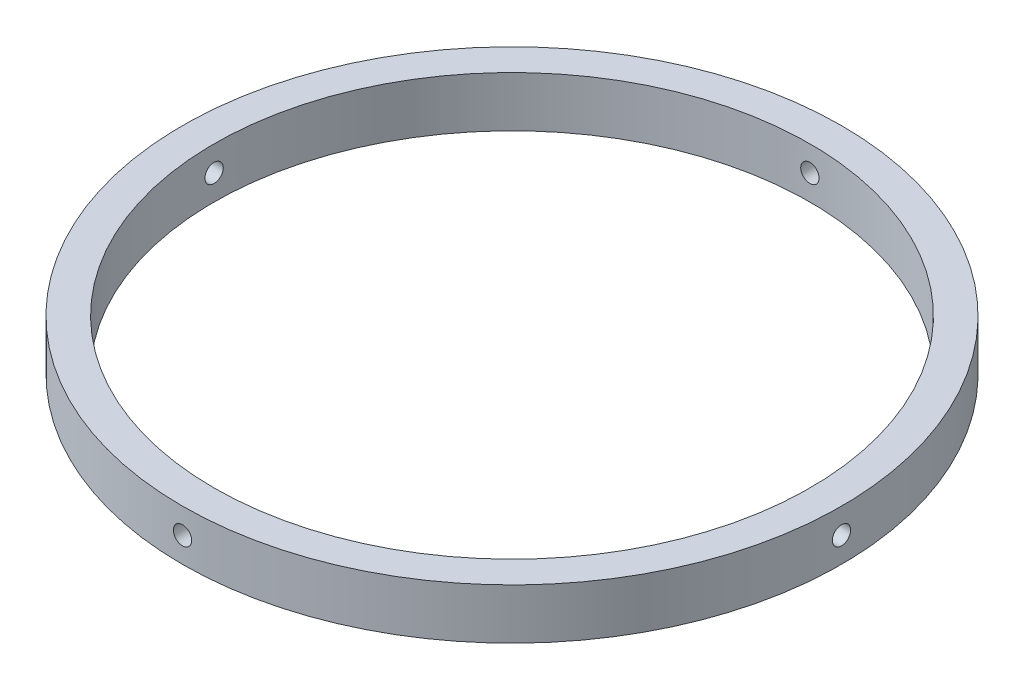
from build123d import *

# Parameters (mm, degrees)
SKETCH1_R               = 52.25
SKETCH1_R_2             = 47.25
BOSS_EXTRUDE1_DEPTH     = 8
SKETCH2_R               = 1.45
CUT_EXTRUDE1_DEPTH      = 53.25
CUT_EXTRUDE1_DEPTH_BACK = 53.25
SKETCH3_R               = 1.45
CUT_EXTRUDE2_DEPTH      = 53.2500001
CUT_EXTRUDE2_DEPTH_BACK = 53.2500001


with BuildPart() as part:
    # Sketch1 → Boss-Extrude1 (new body)
    with BuildSketch(Plane(origin=(0, 0, 0), x_dir=(1, 0, 0), z_dir=(0, 1, 0))):
        Circle(SKETCH1_R)
        Circle(SKETCH1_R_2, mode=Mode.SUBTRACT)
    extrude(amount=BOSS_EXTRUDE1_DEPTH)

    # Sketch2 → Cut-Extrude1 (cut, two sides)
    with BuildSketch(Plane.XY) as cut_extrude1_sk:
        with Locations((0, 4)):
            Circle(SKETCH2_R)
    extrude(amount=CUT_EXTRUDE1_DEPTH, mode=Mode.SUBTRACT)
    extrude(cut_extrude1_sk.sketch, amount=-CUT_EXTRUDE1_DEPTH_BACK, mode=Mode.SUBTRACT)

    # Sketch3 → Cut-Extrude2 (cut, two sides)
    with BuildSketch(Plane(origin=(0, 0, 0), x_dir=(0, 0, -1), z_dir=(1, 0, 0))) as cut_extrude2_sk:
        with Locations((0, 4)):
            Circle(SKETCH3_R)
    extrude(amount=CUT_EXTRUDE2_DEPTH, mode=Mode.SUBTRACT)
    extrude(cut_extrude2_sk.sketch, amount=-CUT_EXTRUDE2_DEPTH_BACK, mode=Mode.SUBTRACT)


solid = part.part
